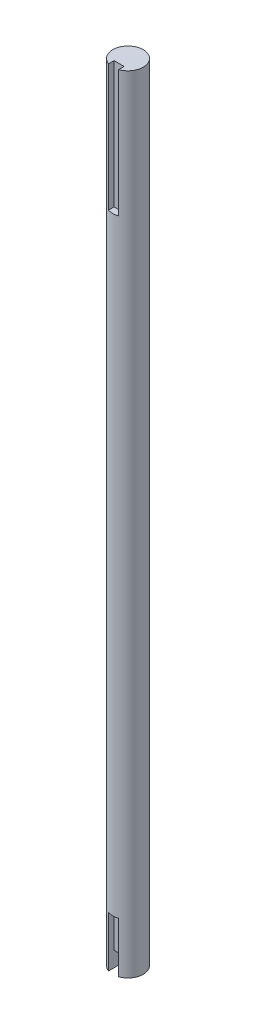
from build123d import *

# Parameters (mm, degrees)
SKETCH1_R                = 6
BOSS_EXTRUDE1_DEPTH      = 254
BOSS_EXTRUDE1_DEPTH_BACK = 56
CUT_EXTRUDE3_START       = -56
SKETCH2_W                = 4
SKETCH2_H                = 5
CUT_EXTRUDE3_DEPTH       = 20
CUT_EXTRUDE3_DEPTH_BACK  = 0.0001
CUT_EXTRUDE4_START       = 254
SKETCH2_2_W              = 4
SKETCH2_2_H              = 5
CUT_EXTRUDE4_DEPTH       = 50
CUT_EXTRUDE6_START       = -56
SKETCH3_W                = 4
SKETCH3_H                = 10
CUT_EXTRUDE6_DEPTH       = 6


with BuildPart() as part:
    # Sketch1 → Boss-Extrude1 (new body, two sides)
    with BuildSketch(Plane(origin=(0, 0, 0), x_dir=(1, 0, 0), z_dir=(0, 1, 0))) as boss_extrude1_sk:
        Circle(SKETCH1_R)
    extrude(amount=BOSS_EXTRUDE1_DEPTH)
    extrude(boss_extrude1_sk.sketch, amount=-BOSS_EXTRUDE1_DEPTH_BACK)

    # Sketch2 → Cut-Extrude3 (cut, two sides)
    with BuildSketch(Plane(origin=(0, 0, 0), x_dir=(1, 0, 0), z_dir=(0, 1, 0)).offset(CUT_EXTRUDE3_START)) as cut_extrude3_sk:
        with Locations((0, -6)):
            Rectangle(SKETCH2_W, SKETCH2_H)
    extrude(amount=CUT_EXTRUDE3_DEPTH, mode=Mode.SUBTRACT)
    extrude(cut_extrude3_sk.sketch, amount=-CUT_EXTRUDE3_DEPTH_BACK, mode=Mode.SUBTRACT)

    # Sketch2_2 → Cut-Extrude4 (cut)
    with BuildSketch(Plane(origin=(0, 0, 0), x_dir=(1, 0, 0), z_dir=(0, 1, 0)).offset(CUT_EXTRUDE4_START)):
        with Locations((0, -6)):
            Rectangle(SKETCH2_2_W, SKETCH2_2_H)
    extrude(amount=-CUT_EXTRUDE4_DEPTH, mode=Mode.SUBTRACT)

    # Sketch3 → Cut-Extrude6 (cut)
    with BuildSketch(Plane(origin=(0, 0, 0), x_dir=(1, 0, 0), z_dir=(0, 1, 0)).offset(CUT_EXTRUDE6_START)):
        with Locations((0, -6)):
            Rectangle(SKETCH3_W, SKETCH3_H)
    extrude(amount=CUT_EXTRUDE6_DEPTH, mode=Mode.SUBTRACT)


solid = part.part
